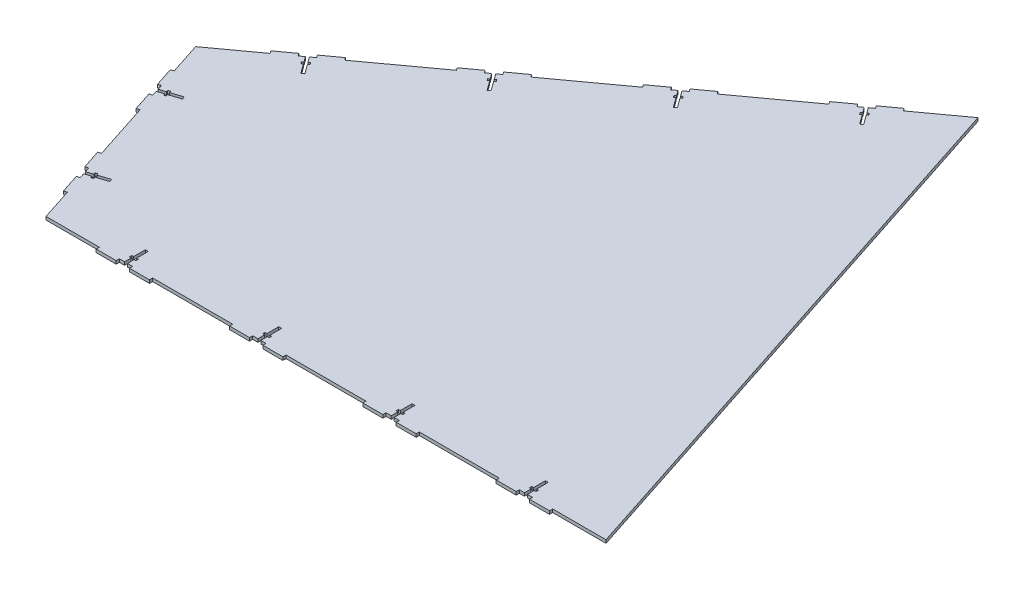
from build123d import *

# Parameters (mm, degrees)
BOSS_EXTRUDE1_DEPTH = 3
CUT_EXTRUDE1_DEPTH  = 4
BOSS_EXTRUDE2_DEPTH = 3
SKETCH9_W           = 19.05
SKETCH9_H           = 3
BOSS_EXTRUDE3_DEPTH = 3


with BuildPart() as part:
    # Sketch5 → Boss-Extrude1 (new body)
    with BuildSketch(Plane(origin=(0, 0, 0), x_dir=(1, 0, 0), z_dir=(0, 1, 0))):
        Polygon((0, 0), (533.4, 0), (362.403571429, 525.320115659), (-68.791666667, 211.335678713), align=None)
    extrude(amount=BOSS_EXTRUDE1_DEPTH)

    # Sketch6 → Cut-Extrude1 (cut, through all)
    with BuildSketch(Plane(origin=(0, 3, 0), x_dir=(1, 0, 0), z_dir=(0, 1, 0))):
        Polygon((74.8284, 0), (77.5716, 0), (77.5716, 6.35), (79.3496, 6.35), (79.3496, 8.636), (77.5716, 8.636), (77.5716, 19.86), (74.8284, 19.86), (74.8284, 8.636), (73.0504, 8.636), (73.0504, 6.35), (74.8284, 6.35), align=None)
        Polygon((204.5716, 19.86), (204.5716, 8.636), (206.3496, 8.636), (206.3496, 6.35), (204.5716, 6.35), (204.5716, 0), (201.8284, 0), (201.8284, 6.35), (200.0504, 6.35), (200.0504, 8.636), (201.8284, 8.636), (201.8284, 19.86), align=None)
        Polygon((299.695463946, 479.657807543), (301.913039456, 481.272584647), (305.650949419, 476.139308003), (307.08826688, 477.185922793), (308.433914467, 475.337943201), (306.996597006, 474.291328412), (313.60357361, 465.217958797), (311.3859981, 463.603181693), (304.779021496, 472.676551307), (303.341704036, 471.629936517), (301.996056449, 473.477916109), (303.433373909, 474.524530899), align=None)
        Polygon((331.5716, 19.86), (331.5716, 8.636), (333.3496, 8.636), (333.3496, 6.35), (331.5716, 6.35), (331.5716, 0), (328.8284, 0), (328.8284, 6.35), (327.0504, 6.35), (327.0504, 8.636), (328.8284, 8.636), (328.8284, 19.86), align=None)
        Polygon((458.5716, 19.86), (458.5716, 8.636), (460.3496, 8.636), (460.3496, 6.35), (458.5716, 6.35), (458.5716, 0), (455.8284, 0), (455.8284, 6.35), (454.0504, 6.35), (454.0504, 8.636), (455.8284, 8.636), (455.8284, 19.86), align=None)
        Polygon((197.029931066, 404.89960827), (199.247506576, 406.514385375), (202.98541654, 401.381108731), (204.422734, 402.42772352), (205.768381587, 400.579743929), (204.331064127, 399.533129139), (210.93804073, 390.459759524), (208.72046522, 388.84498242), (202.113488616, 397.918352034), (200.676171156, 396.871737245), (199.330523569, 398.719716836), (200.767841029, 399.766331626), align=None)
        Polygon((94.364398186, 330.141408998), (96.581973696, 331.756186102), (100.31988366, 326.622909458), (101.75720112, 327.669524248), (103.102848707, 325.821544656), (101.665531247, 324.774929866), (108.27250785, 315.701560252), (106.05493234, 314.086783147), (99.447955736, 323.160152762), (98.010638276, 322.113537972), (96.664990689, 323.961517564), (98.10230815, 325.008132354), align=None)
        Polygon((-2.34564922, 251.864710185), (-6.083559184, 256.997986829), (-8.301134694, 255.383209725), (-4.56322473, 250.249933081), (-6.000542191, 249.203318291), (-4.654894604, 247.355338699), (-3.217577143, 248.401953489), (3.38939946, 239.328583874), (5.60697497, 240.943360979), (-1.000001633, 250.016730593), (0.437315827, 251.063345383), (-0.90833176, 252.911324975), align=None)
        Polygon((-50.677838095, 155.687975427), (-51.52692381, 158.296461519), (-45.488761561, 160.261937709), (-46.039094894, 161.952623139), (-43.865356484, 162.660194567), (-43.315023151, 160.969509138), (-32.642214792, 164.443604376), (-31.793129077, 161.835118284), (-42.465937437, 158.361023046), (-41.915604103, 156.670337616), (-44.089342513, 155.962766188), (-44.639675846, 157.653451617), align=None)
        Polygon((-9.901927913, 58.320750905), (0.770880447, 61.794846143), (1.619966161, 59.186360052), (-9.052842199, 55.712264814), (-8.502508865, 54.021579384), (-10.676247275, 53.314007956), (-11.226580608, 55.004693385), (-17.264742857, 53.039217195), (-18.113828571, 55.647703286), (-12.075666322, 57.613179477), (-12.625999656, 59.303864907), (-10.452261246, 60.011436335), align=None)
    extrude(amount=-CUT_EXTRUDE1_DEPTH, mode=Mode.SUBTRACT)

    # Sketch8 → Boss-Extrude2 (add)
    with BuildSketch(Plane(origin=(0, 0, 0), x_dir=(1, 0, 0), z_dir=(0, 1, 0))):
        Polygon((-15.723809524, 48.305297992), (-18.576484602, 47.376726563), (-12.680056031, 29.262239816), (-9.827380952, 30.190811245), align=None)
        Polygon((-25.551190476, 78.496109236), (-28.403865554, 77.567537808), (-22.507436983, 59.453051061), (-19.654761905, 60.38162249), align=None)
        Polygon((-58.964285714, 181.144867469), (-61.816960793, 180.21629604), (-55.920532221, 162.101809293), (-53.067857143, 163.030380722), align=None)
        Polygon((-49.136904762, 150.954056224), (-51.98957984, 150.025484795), (-46.093151269, 131.910998048), (-43.24047619, 132.839569477), align=None)
    extrude(amount=BOSS_EXTRUDE2_DEPTH)

    # Sketch9 → Boss-Extrude3 (add)
    with BuildSketch(Plane(origin=(0, 0, 0), x_dir=(1, 0, 0), z_dir=(0, 1, 0))):
        with Locations((60.325, -1.5)):
            Rectangle(SKETCH9_W, SKETCH9_H)
        with Locations((92.075, -1.5)):
            Rectangle(SKETCH9_W, SKETCH9_H)
        with Locations((187.325, -1.5)):
            Rectangle(SKETCH9_W, SKETCH9_H)
        with Locations((219.075, -1.5)):
            Rectangle(SKETCH9_W, SKETCH9_H)
        with Locations((314.325, -1.5)):
            Rectangle(SKETCH9_W, SKETCH9_H)
        with Locations((346.075, -1.5)):
            Rectangle(SKETCH9_W, SKETCH9_H)
        with Locations((441.325, -1.5)):
            Rectangle(SKETCH9_W, SKETCH9_H)
        with Locations((473.075, -1.5)):
            Rectangle(SKETCH9_W, SKETCH9_H)
        Polygon((321.337358277, 495.41683595), (319.571416562, 497.842006018), (304.17158663, 486.628276127), (305.937528345, 484.203106059), align=None)
        Polygon((295.670975057, 476.727286132), (293.905033342, 479.1524562), (278.50520341, 467.938726309), (280.271145125, 465.513556241), align=None)
        Polygon((218.671825397, 420.658636677), (216.905883682, 423.083806745), (201.50605375, 411.870076854), (203.271995465, 409.444906786), align=None)
        Polygon((193.005442177, 401.969086859), (191.239500462, 404.394256927), (175.83967053, 393.180527036), (177.605612245, 390.755356968), align=None)
        Polygon((116.006292517, 345.900437404), (114.240350802, 348.325607472), (98.84052087, 337.111877581), (100.606462585, 334.686707513), align=None)
        Polygon((90.339909297, 327.210887586), (88.573967582, 329.636057654), (73.17413765, 318.422327763), (74.940079365, 315.997157695), align=None)
        Polygon((13.340759637, 271.142238132), (11.574817922, 273.5674082), (-3.82501201, 262.353678309), (-2.059070295, 259.928508241), align=None)
        Polygon((-12.325623583, 252.452688313), (-14.091565298, 254.877858381), (-29.49139523, 243.66412849), (-27.725453515, 241.238958422), align=None)
    extrude(amount=BOSS_EXTRUDE3_DEPTH)


solid = part.part
